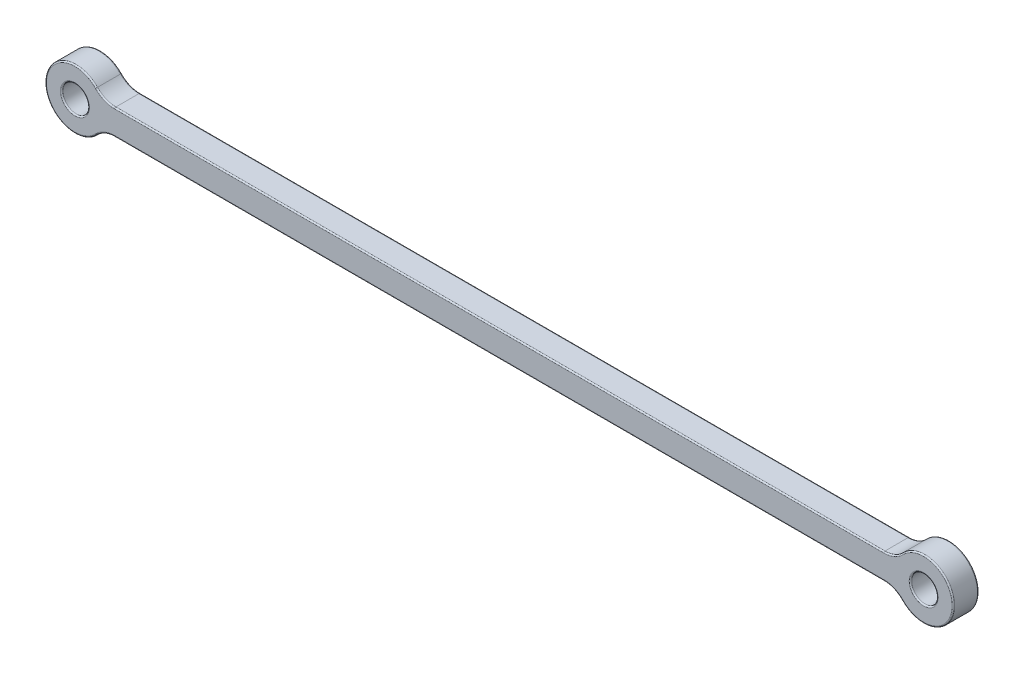
from build123d import *

# Parameters (mm, degrees)
SKETCH1_R           = 3.5
SKETCH1_R_2         = 1.55
BOSS_EXTRUDE1_DEPTH = 1.5
FILLET1_R           = 3
FILLET3_R           = 0.15


with BuildPart() as part:
    # Sketch1 → Boss-Extrude1 (new body, symmetric)
    with BuildSketch(Plane.XY):
        Circle(SKETCH1_R)
        Circle(SKETCH1_R_2, mode=Mode.SUBTRACT)
        with BuildLine():
            Line((3.16227766, -1.5), (96.83772234, -1.5))
            ThreePointArc((96.83772234, -1.5), (96.5, 0), (96.83772234, 1.5))
            Line((96.83772234, 1.5), (3.16227766, 1.5))
            ThreePointArc((3.16227766, 1.5), (3.414525722, 0.768774411), (3.5, 0))
            ThreePointArc((3.5, 0), (3.414525722, -0.768774411), (3.16227766, -1.5))
        make_face()
        with Locations((100, 0)):
            Circle(SKETCH1_R)
        with Locations((100, 0)):
            Circle(SKETCH1_R_2, mode=Mode.SUBTRACT)
    extrude(amount=BOSS_EXTRUDE1_DEPTH, both=True)

    # Fillet1
    fillet1_edges = [part.edges().sort_by_distance(p)[0] for p in [
        (96.83772234, 1.5, 0),
        (96.83772234, -1.5, 0),
        (3.16227766, -1.5, 0),
        (3.16227766, 1.5, 0),
    ]]
    fillet(fillet1_edges, radius=FILLET1_R)

    # Fillet3
    fillet3_edges = [part.edges().sort_by_distance(p)[0] for p in [
        (103.5, 0, -1.5),
        (-1.55, 0, 1.5),
        (103.5, 0, 1.5),
        (50, -1.5, -1.5),
        (50, -1.5, 1.5),
        (98.45, 0, 1.5),
        (-3.5, 0, -1.5),
        (-3.5, 0, 1.5),
        (50, 1.5, -1.5),
        (50, 1.5, 1.5),
        (96.486281051, -1.740401367, -1.5),
        (96.486281051, -1.740401367, 1.5),
        (3.513718949, -1.740401367, -1.5),
        (3.513718949, -1.740401367, 1.5),
        (96.486281051, 1.740401367, -1.5),
        (96.486281051, 1.740401367, 1.5),
        (3.513718949, 1.740401367, -1.5),
        (3.513718949, 1.740401367, 1.5),
        (98.45, 0, -1.5),
        (-1.55, 0, -1.5),
    ]]
    fillet(fillet3_edges, radius=FILLET3_R)


solid = part.part
